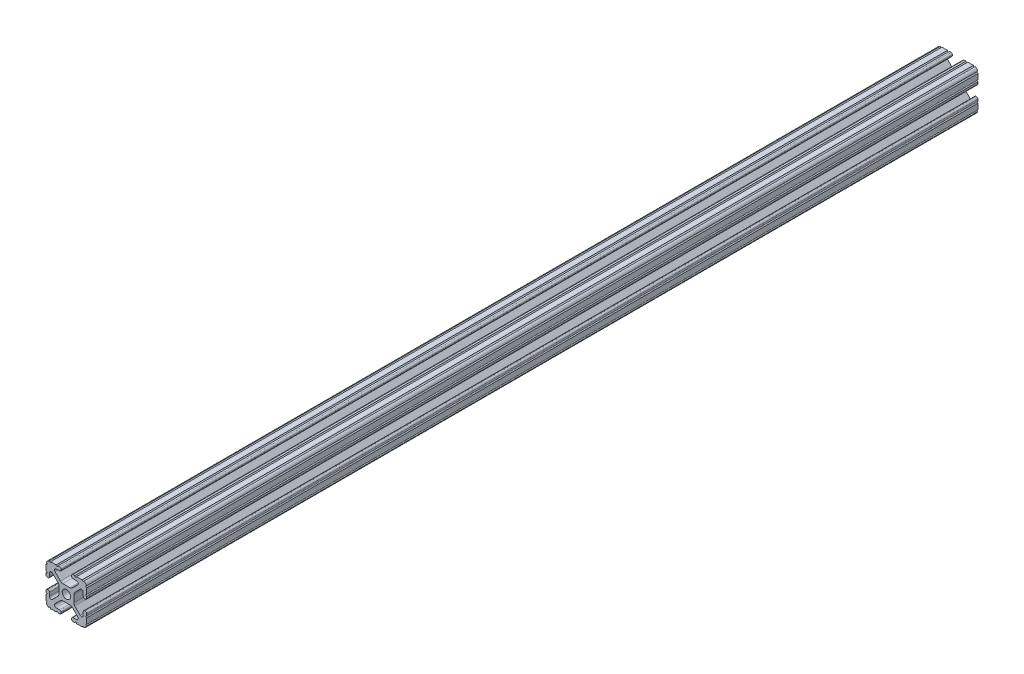
from build123d import *

# Parameters (mm, degrees)
BOSS_EXTRUDE1_DEPTH      = 277.8125
CUT_EXTRUDE1_START       = -277.8125
SKETCH5_R                = 0.55245
CUT_EXTRUDE1_DEPTH       = 555.625
F_0_257_DIAMETER_HOLE1_D = 6.5278


with BuildPart() as part:
    # Sketch4 → Boss-Extrude1 (new body, symmetric)
    with BuildSketch(Plane.XY):
        with BuildLine():
            Line((4.190365, -12.7), (10.11729625, -12.7))
            ThreePointArc((10.11729625, -12.7), (11.943543585, -11.943543585), (12.7, -10.11729625))
            Line((12.7, -10.11729625), (12.7, -4.190365))
            ThreePointArc((12.7, -4.190365), (12.42492494, -3.52627506), (11.760835, -3.2512))
            Line((11.760835, -3.2512), (11.429365, -3.2512))
            ThreePointArc((11.429365, -3.2512), (10.76527506, -3.52627506), (10.4902, -4.190365))
            Line((10.4902, -4.190365), (10.4902, -6.348478019))
            ThreePointArc((10.4902, -6.348478019), (9.830707141, -7.335478831), (8.666460301, -7.103895736))
            Line((8.666460301, -7.103895736), (5.299899128, -3.737334563))
            ThreePointArc((5.299899128, -3.737334563), (4.817571085, -3.015479634), (4.6482, -2.16399369))
            Line((4.6482, -2.16399369), (4.6482, 0))
            Line((4.6482, 0), (2.6035, 0))
            ThreePointArc((2.6035, 0), (1.840952505, -1.840952505), (0, -2.6035))
            Line((0, -2.6035), (0, -4.6482))
            Line((0, -4.6482), (2.16399369, -4.6482))
            ThreePointArc((2.16399369, -4.6482), (3.015479634, -4.817571085), (3.737334563, -5.299899128))
            Line((3.737334563, -5.299899128), (7.103895736, -8.666460301))
            ThreePointArc((7.103895736, -8.666460301), (7.335478831, -9.830707141), (6.348478019, -10.4902))
            Line((6.348478019, -10.4902), (4.190365, -10.4902))
            ThreePointArc((4.190365, -10.4902), (3.52627506, -10.76527506), (3.2512, -11.429365))
            Line((3.2512, -11.429365), (3.2512, -11.760835))
            ThreePointArc((3.2512, -11.760835), (3.52627506, -12.42492494), (4.190365, -12.7))
        make_face()
    extrude(amount=BOSS_EXTRUDE1_DEPTH, both=True)

    # Sketch5 → Cut-Extrude1 (cut)
    with BuildSketch(Plane.XY.offset(CUT_EXTRUDE1_START)):
        with Locations((10.356153152, -12.7)):
            Circle(SKETCH5_R)
        with Locations((5.796028019, -12.7)):
            Circle(SKETCH5_R)
        with Locations((12.7, -10.356153152)):
            Circle(SKETCH5_R)
        with Locations((12.7, -5.796028019)):
            Circle(SKETCH5_R)
    extrude(amount=CUT_EXTRUDE1_DEPTH, mode=Mode.SUBTRACT)

    # Mirror1: part across plane


with BuildPart() as part_1:
    add(part.part)
    add(part.part.mirror(Plane(origin=(0, 0, 0), x_dir=(0, 0, 1), z_dir=(1, 0, 0))))

    # Mirror2: part across plane


with BuildPart() as part_2:
    add(part_1.part)
    add(part_1.part.mirror(Plane.ZX))

    # F _0.257_ Diameter Hole1 (through all)
    with Locations(Plane(origin=(12.7, 0, 0), x_dir=(0, 0, -1), z_dir=(1, 0, 0))):
        with Locations((-190.5, 0), (190.5, 0)):
            Hole(F_0_257_DIAMETER_HOLE1_D / 2)


solid = part_2.part
